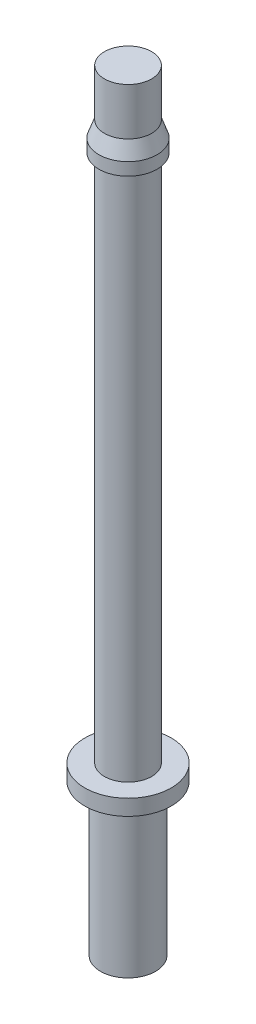
from build123d import *


with BuildPart() as part:
    # Sketch1 → Revolve1 (revolve)
    with BuildSketch(Plane.XY):
        Polygon((0, 0), (1.75, 0), (1.75, 9.6), (2.75, 9.6), (2.75, 10.6), (1.5, 10.6), (1.5, 44.2), (1.85, 44.2), (1.85, 45), (1.5, 46), (1.5, 49), (0, 49), align=None)
    revolve(axis=Axis((0, 0, 0), (0, 1, 0)))


solid = part.part
